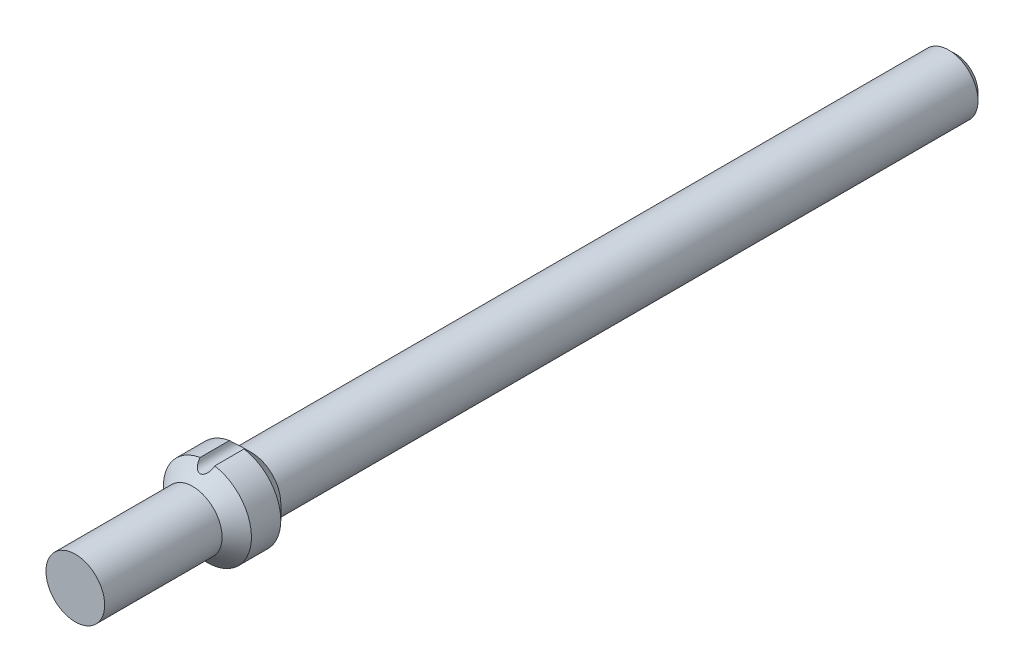
from build123d import *

# Parameters (mm, degrees)
CUT_EXTRUDE1_REACH = 383
SKETCH4_R          = 3.175


with BuildPart() as part:
    # Sketch2 → Revolve1 (revolve)
    with BuildSketch(Plane(origin=(0, 0, 0), x_dir=(1, 0, 0), z_dir=(0, 1, 0))):
        Polygon((0, -190.5), (12.7, -190.5), (12.7, -139.7), (19.05, -133.35), (19.05, -120.65), (12.7, -114.3), (12.7, 187.325), (9.525, 190.5), (0, 190.5), align=None)
    revolve(axis=Axis((0, 0, 190.5), (0, 0, -1)))

    # Sketch4 → Cut-Extrude1 (cut, up to next)
    with BuildSketch(Plane.XY.offset(190.5), mode=Mode.PRIVATE) as cut_extrude1_sk1:
        with Locations((0, 19.05)):
            Circle(SKETCH4_R)
    cut_extrude1_tool1 = extrude(cut_extrude1_sk1.sketch, amount=-CUT_EXTRUDE1_REACH, mode=Mode.PRIVATE) & part.part
    add(cut_extrude1_tool1.solids().sort_by_distance((0, 19.05, 190.5))[0], mode=Mode.SUBTRACT)


solid = part.part
